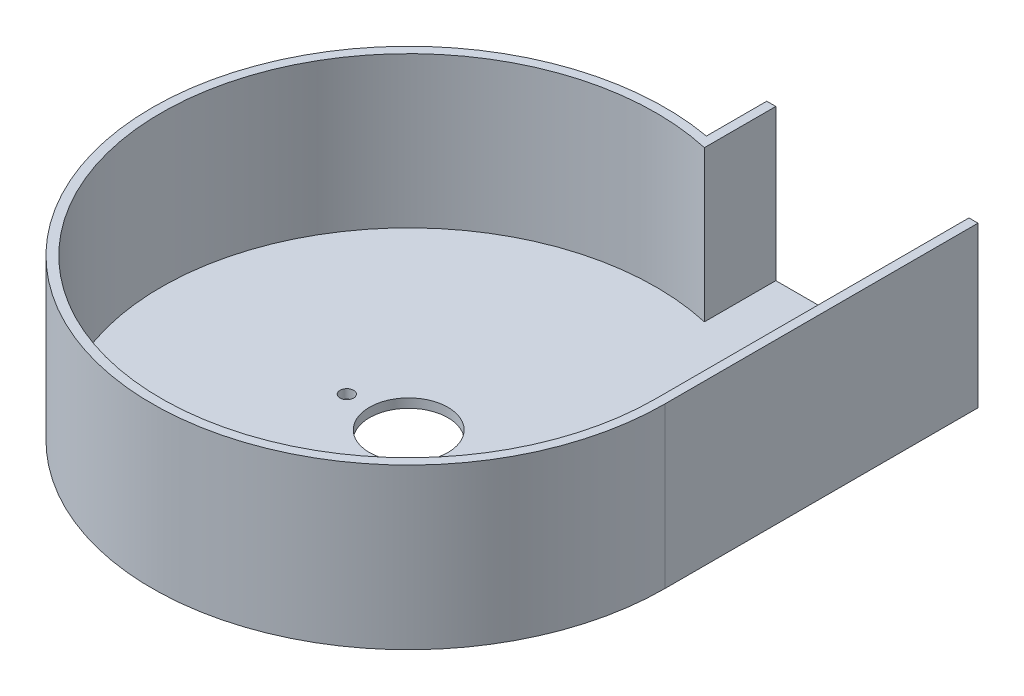
from build123d import *

# Parameters (mm, degrees)
SKETCH2_R           = 2.25
SKETCH2_R_2         = 13
BOSS_EXTRUDE1_DEPTH = 3
BOSS_EXTRUDE2_DEPTH = 50


with BuildPart() as part:
    # Sketch2 → Boss-Extrude1 (new body)
    with BuildSketch(Plane(origin=(0, 0, 0), x_dir=(1, 0, 0), z_dir=(0, 1, 0))):
        with BuildLine():
            Line((85, 0), (85, 103.666002653))
            Line((85, 103.666002653), (15, 103.666002653))
            Line((15, 103.666002653), (15, 83.666002653))
            ThreePointArc((15, 83.666002653), (-65.192024052, -54.543560573), (85, 0))
        make_face()
        with Locations((20.5, 0)):
            Circle(SKETCH2_R, mode=Mode.SUBTRACT)
        with Locations((-20.5, 0)):
            Circle(SKETCH2_R, mode=Mode.SUBTRACT)
        Circle(SKETCH2_R_2, mode=Mode.SUBTRACT)
    extrude(amount=BOSS_EXTRUDE1_DEPTH)

    # Sketch3 → Boss-Extrude2 (add)
    with BuildSketch(Plane(origin=(0, 3, 0), x_dir=(1, 0, 0), z_dir=(0, 1, 0))):
        with BuildLine():
            Line((15, 103.666002653), (18, 103.666002653))
            Line((18, 103.666002653), (18, 80))
            ThreePointArc((18, 80), (-64.031242374, -51.224993899), (82, 0))
            Line((82, 0), (82, 103.666002653))
            Line((82, 103.666002653), (85, 103.666002653))
            Line((85, 103.666002653), (85, 0))
            ThreePointArc((85, 0), (-65.192024052, -54.543560573), (15, 83.666002653))
            Line((15, 83.666002653), (15, 103.666002653))
        make_face()
    extrude(amount=BOSS_EXTRUDE2_DEPTH)


solid = part.part
